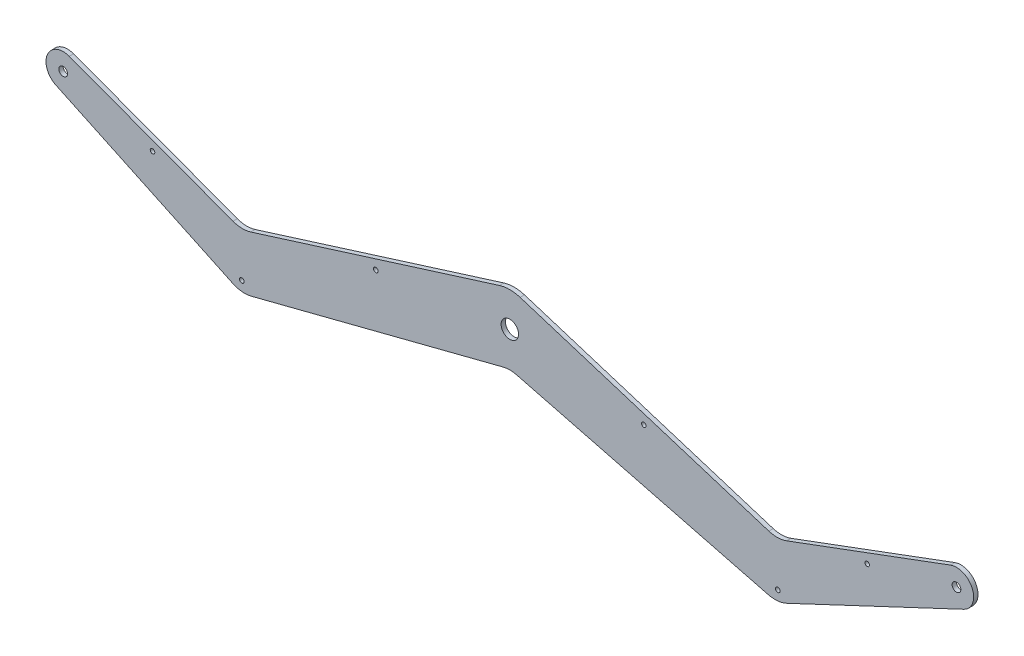
from build123d import *

# Parameters (mm, degrees)
BOSS_EXTRUDE1_DEPTH = 3.18
SKETCH2_R           = 6.35
SKETCH2_R_2         = 3.175
SKETCH2_R_3         = 1.65
CUT_EXTRUDE1_DEPTH  = 4.18


with BuildPart() as part:
    # Sketch1 → Boss-Extrude1 (new body)
    with BuildSketch(Plane.XY):
        with BuildLine():
            Line((-7.486391976, 23.852755295), (-188.46282125, -32.948250341))
            ThreePointArc((-188.46282125, -32.948250341), (-194.970418947, -33.859324331), (-201.422047732, -32.612179737))
            Line((-201.422047732, -32.612179737), (-320.643679437, 11.71633352))
            ThreePointArc((-320.643679437, 11.71633352), (-336.523287364, 4.843949662), (-330.323051891, -11.309956612))
            Line((-330.323051891, -11.309956612), (-201.512349729, -71.934950616))
            ThreePointArc((-201.512349729, -71.934950616), (-194.881579427, -73.749885885), (-188.027959697, -73.212297358))
            Line((-188.027959697, -73.212297358), (-4.967507005, -26.273719745))
            ThreePointArc((-4.967507005, -26.273719745), (0, -25.646997066), (4.967507005, -26.273719745))
            Line((4.967507005, -26.273719745), (188.027959697, -73.212297358))
            ThreePointArc((188.027959697, -73.212297358), (194.881579427, -73.749885885), (201.512349729, -71.934950616))
            Line((201.512349729, -71.934950616), (330.323051891, -11.309956612))
            ThreePointArc((330.323051891, -11.309956612), (336.523287364, 4.843949662), (320.643679437, 11.71633352))
            Line((320.643679437, 11.71633352), (201.422047732, -32.612179737))
            ThreePointArc((201.422047732, -32.612179737), (194.970418947, -33.859324331), (188.46282125, -32.948250341))
            Line((188.46282125, -32.948250341), (7.486391976, 23.852755295))
            ThreePointArc((7.486391976, 23.852755295), (0, 25), (-7.486391976, 23.852755295))
        make_face()
    extrude(amount=BOSS_EXTRUDE1_DEPTH)

    # Sketch2 → Cut-Extrude1 (cut, through all)
    with BuildSketch(Plane.XY.offset(3.18)):
        Circle(SKETCH2_R)
        with Locations((-325, 0)):
            Circle(SKETCH2_R_2)
        with Locations((-97.5, -11.398788164)):
            Circle(SKETCH2_R_3)
        with Locations((-195, -66.738312644)):
            Circle(SKETCH2_R_3)
        with Locations((-260, -17.831958341)):
            Circle(SKETCH2_R_3)
        with Locations((97.5, -11.398788164)):
            Circle(SKETCH2_R_3)
        with Locations((195, -66.738312644)):
            Circle(SKETCH2_R_3)
        with Locations((260, -17.831958341)):
            Circle(SKETCH2_R_3)
        with Locations((325, 0)):
            Circle(SKETCH2_R_2)
    extrude(amount=-CUT_EXTRUDE1_DEPTH, mode=Mode.SUBTRACT)


solid = part.part
